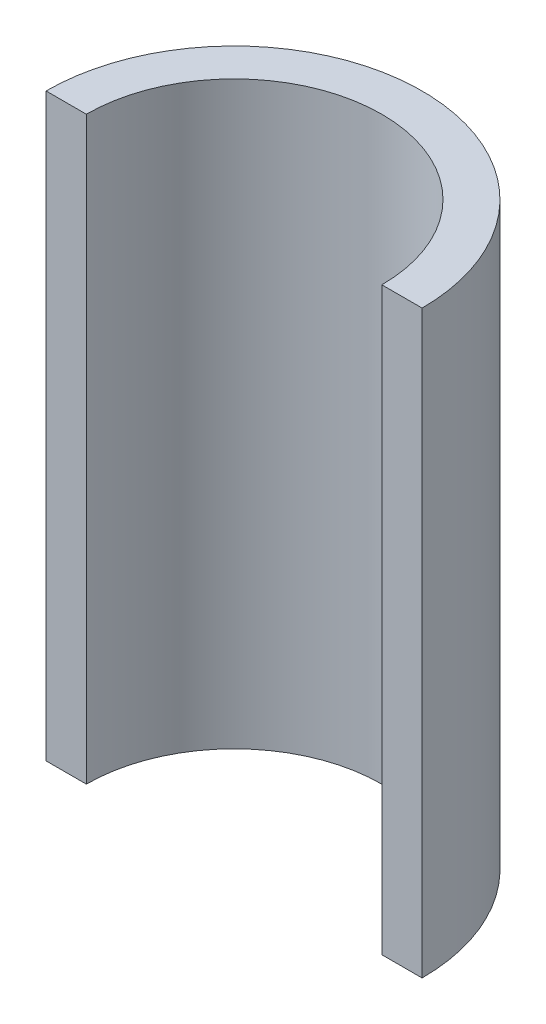
from build123d import *

# Parameters (mm, degrees)
BOSS_EXTRU_1_DEPTH = 34.56


with BuildPart() as part:
    # Esquisse1 → Boss.-Extru.1 (new body, symmetric)
    with BuildSketch(Plane(origin=(0, 0, 0), x_dir=(1, 0, 0), z_dir=(0, 1, 0))):
        with BuildLine():
            Line((17.6, 0), (22.4, 0))
            ThreePointArc((22.4, 0), (0, 22.4), (-22.4, 0))
            Line((-22.4, 0), (-17.6, 0))
            ThreePointArc((-17.6, 0), (0, 17.6), (17.6, 0))
        make_face()
    extrude(amount=BOSS_EXTRU_1_DEPTH, both=True)


solid = part.part
